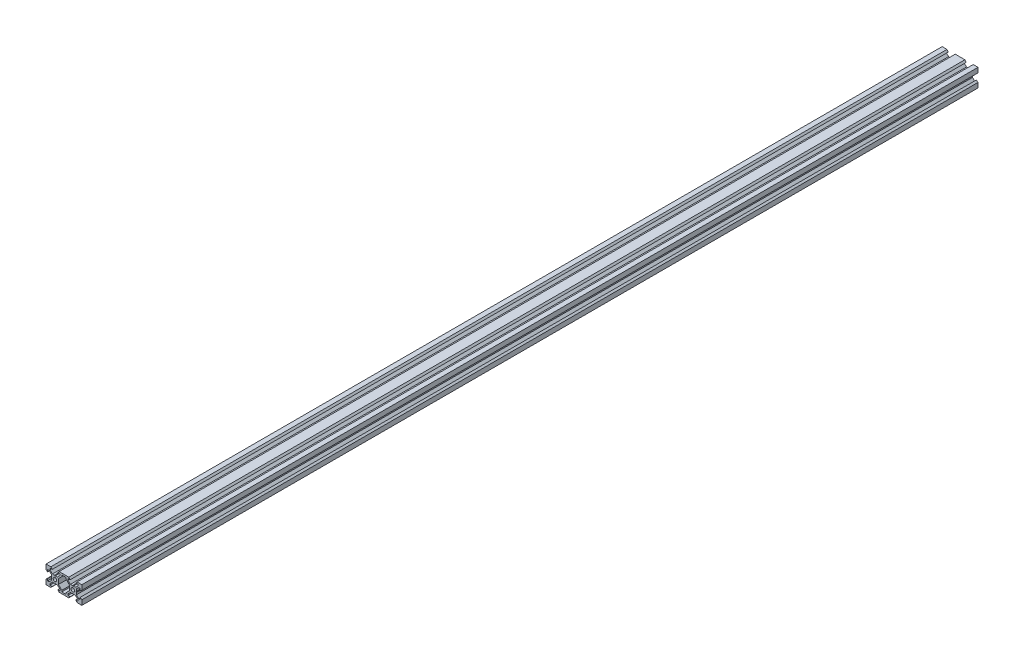
from build123d import *

# Parameters (mm, degrees)
SKETCH1_R           = 2
BOSS_EXTRUDE1_DEPTH = 1000


with BuildPart() as part:
    # Sketch1 → Boss-Extrude1 (new body)
    with BuildSketch(Plane.XY):
        Polygon((-5.389620664, 10), (5.389620664, 10), (6.9, 8.2), (4.5, 8.2), (4.5, 6.556171609), (7.151917065, 3.899773171), (9.480384758, 3.899773171), (10, 3.599773171), (10.519615242, 3.899773171), (12.848082935, 3.899773171), (15.5, 6.556171609), (15.5, 8.2), (13.1, 8.2), (14.610379336, 10), (20, 10), (20, 4.610379336), (18.2, 3.1), (18.2, 5.5), (16.556171609, 5.5), (13.9, 2.839339828), (13.9, 0.519615231), (13.599999981, 0), (13.9, -0.519615231), (13.9, -2.839339828), (16.556171609, -5.5), (18.2, -5.5), (18.2, -3.1), (20, -4.610379336), (20, -10), (14.610379336, -10), (13.1, -8.2), (15.5, -8.2), (15.5, -6.556171609), (12.839339828, -3.9), (10.519222362, -3.9), (10, -3.600226829), (9.480777638, -3.9), (7.160660172, -3.9), (4.5, -6.556171609), (4.5, -8.2), (6.9, -8.2), (5.389620664, -10), (-5.389620664, -10), (-6.9, -8.2), (-4.5, -8.2), (-4.5, -6.556171609), (-7.160432959, -3.900226829), (-9.480384758, -3.900226829), (-10, -3.600226829), (-10.519615242, -3.900226829), (-12.839339828, -3.9), (-15.5, -6.556171609), (-15.5, -8.2), (-13.1, -8.2), (-14.610379336, -10), (-20, -10), (-20, -4.610379336), (-18.2, -3.1), (-18.2, -5.5), (-16.556171609, -5.5), (-13.9, -2.839339828), (-13.9, -0.519615231), (-13.599999981, 0), (-13.9, 0.519615231), (-13.9, 2.839339828), (-16.556171609, 5.5), (-18.2, 5.5), (-18.2, 3.1), (-20, 4.610379336), (-20, 10), (-14.610379336, 10), (-13.1, 8.2), (-15.5, 8.2), (-15.5, 6.556171609), (-12.839339828, 3.9), (-10.519615242, 3.899773171), (-10, 3.599773171), (-9.480384758, 3.899773171), (-7.160660172, 3.9), (-4.5, 6.556171609), (-4.5, 8.2), (-6.9, 8.2), align=None)
        with Locations((-10, 0)):
            Circle(SKETCH1_R, mode=Mode.SUBTRACT)
        with Locations((10, 0)):
            Circle(SKETCH1_R, mode=Mode.SUBTRACT)
        Polygon((-6.1, -2.839339828), (-2.376887287, -6.556171609), (-2.376887287, -8.2), (2.376887287, -8.2), (2.376887287, -6.556171609), (6.1, -2.839339828), (6.1, 2.839339828), (2.383168219, 6.556171609), (2.383168219, 8.2), (-2.383168219, 8.2), (-2.383168219, 6.556171609), (-6.1, 2.839339828), align=None, mode=Mode.SUBTRACT)
    extrude(amount=BOSS_EXTRUDE1_DEPTH)


solid = part.part
